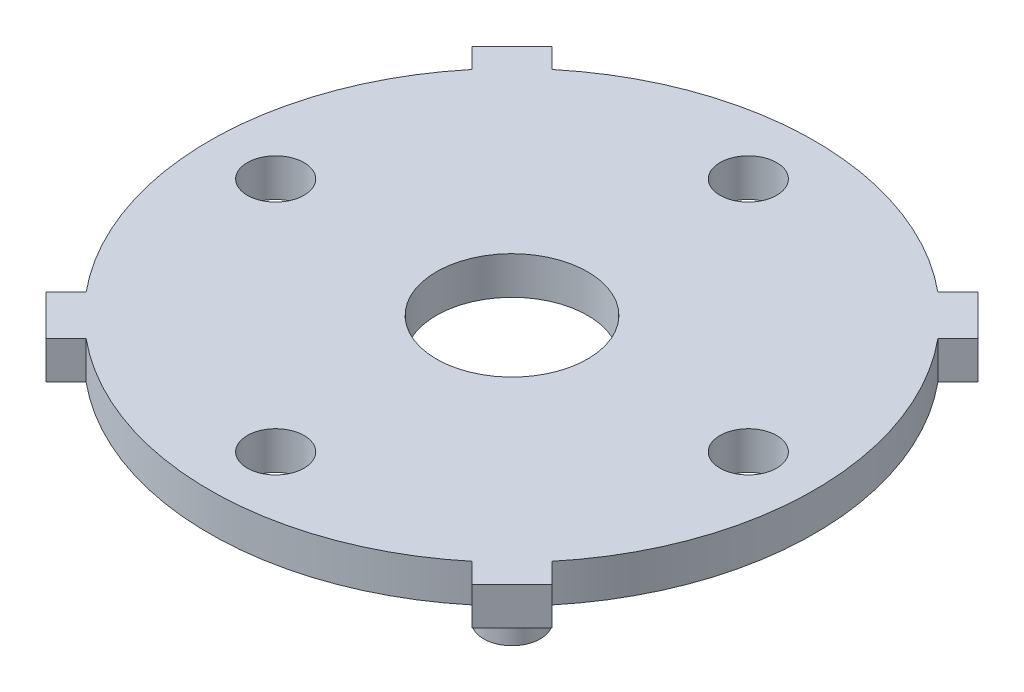
from build123d import *

# Parameters (mm, degrees)
SKETCH1_R           = 16
SKETCH1_R_2         = 1.5
SKETCH1_R_3         = 4
BOSS_EXTRUDE1_DEPTH = 2
SKETCH2_R           = 1.5
BOSS_EXTRUDE2_DEPTH = 5


with BuildPart() as part:
    # Sketch1 → Boss-Extrude1 (new body)
    with BuildSketch(Plane(origin=(0, 0, 0), x_dir=(1, 0, 0), z_dir=(0, 1, 0))):
        Circle(SKETCH1_R)
        with Locations((-12.5, 0)):
            Circle(SKETCH1_R_2, mode=Mode.SUBTRACT)
        with Locations((0, -12.5)):
            Circle(SKETCH1_R_2, mode=Mode.SUBTRACT)
        with Locations((12.5, 0)):
            Circle(SKETCH1_R_2, mode=Mode.SUBTRACT)
        with Locations((0, 12.5)):
            Circle(SKETCH1_R_2, mode=Mode.SUBTRACT)
        Circle(SKETCH1_R_3, mode=Mode.SUBTRACT)
        with BuildLine():
            ThreePointArc((-10.203220154, -12.324540498), (-11.313708499, -11.313708499), (-12.324540498, -10.203220154))
            Line((-12.324540498, -10.203220154), (-13.38520067, -11.263880326))
            Line((-13.38520067, -11.263880326), (-11.263880326, -13.38520067))
            Line((-11.263880326, -13.38520067), (-10.203220154, -12.324540498))
        make_face()
        with BuildLine():
            Line((13.38520067, -11.263880326), (12.324540498, -10.203220154))
            ThreePointArc((12.324540498, -10.203220154), (11.313708499, -11.313708499), (10.203220154, -12.324540498))
            Line((10.203220154, -12.324540498), (11.263880326, -13.38520067))
            Line((11.263880326, -13.38520067), (13.38520067, -11.263880326))
        make_face()
        with BuildLine():
            Line((13.38520067, 11.263880326), (11.263880326, 13.38520067))
            Line((11.263880326, 13.38520067), (10.203220154, 12.324540498))
            ThreePointArc((10.203220154, 12.324540498), (11.313708499, 11.313708499), (12.324540498, 10.203220154))
            Line((12.324540498, 10.203220154), (13.38520067, 11.263880326))
        make_face()
        with BuildLine():
            ThreePointArc((-12.324540498, 10.203220154), (-11.313708499, 11.313708499), (-10.203220154, 12.324540498))
            Line((-10.203220154, 12.324540498), (-11.263880326, 13.38520067))
            Line((-11.263880326, 13.38520067), (-13.38520067, 11.263880326))
            Line((-13.38520067, 11.263880326), (-12.324540498, 10.203220154))
        make_face()
    extrude(amount=BOSS_EXTRUDE1_DEPTH)

    # Sketch2 → Boss-Extrude2 (add)
    with BuildSketch(Plane.XZ):
        with Locations((7.071067812, 7.071067812)):
            Circle(SKETCH2_R)
    extrude(amount=BOSS_EXTRUDE2_DEPTH)


solid = part.part
